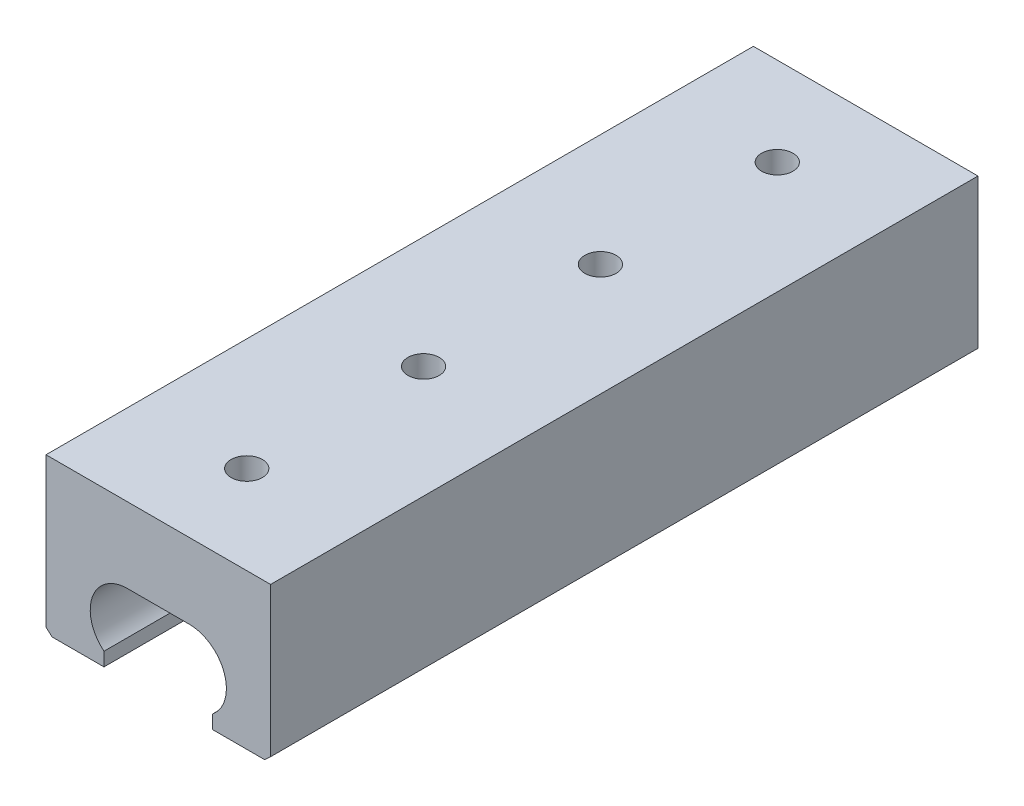
from build123d import *

# Parameters (mm, degrees)
BASE_EXTRUDE_DEPTH           = 203.2
TAP_DRILL_FOR_M10X1_0_TAP2_D = 9
LPATTERN1_COUNT              = 4
LPATTERN1_PITCH              = 50.8


with BuildPart() as part:
    # Sketch1 → Base-Extrude (new body)
    with BuildSketch(Plane.XY):
        with BuildLine():
            Line((-51.848409542, -29.029859377), (-51.848409542, -32.936966461))
            Line((-51.848409542, -32.936966461), (-66.799126207, -32.936966461))
            Line((-66.799126207, -32.936966461), (-68.5063829, -31.355514763))
            Line((-68.5063829, -31.355514763), (-68.5063829, 11.513033539))
            Line((-68.5063829, 11.513033539), (-3.9903829, 11.513033539))
            Line((-3.9903829, 11.513033539), (-3.9903829, -31.355514763))
            Line((-3.9903829, -31.355514763), (-5.697639593, -32.936966461))
            Line((-5.697639593, -32.936966461), (-20.648356257, -32.936966461))
            Line((-20.648356257, -32.936966461), (-20.648356257, -29.029859377))
            ThreePointArc((-20.648356257, -29.029859377), (-17.301518569, -17.177491216), (-27.3583829, -10.068382033))
            Line((-27.3583829, -10.068382033), (-45.1383829, -10.068382033))
            ThreePointArc((-45.1383829, -10.068382033), (-55.19524723, -17.177491216), (-51.848409542, -29.029859377))
        make_face()
    extrude(amount=BASE_EXTRUDE_DEPTH)

    # Tap Drill for M10x1.0 Tap2 (through all)
    with Locations(Plane(origin=(0, 11.513033539, 0), x_dir=(-1, 0, 0), z_dir=(0, 1, 0))):
        with Locations((36.2483829, 177.8)):
            tap_drill_for_m10x1_0_tap2 = Hole(TAP_DRILL_FOR_M10X1_0_TAP2_D / 2)

    # LPattern1: Tap Drill for M10x1.0 Tap2 ×4
    with Locations(*[(0, 0, -i * LPATTERN1_PITCH) for i in range(1, LPATTERN1_COUNT)]):
        add(tap_drill_for_m10x1_0_tap2, mode=Mode.SUBTRACT)


solid = part.part
